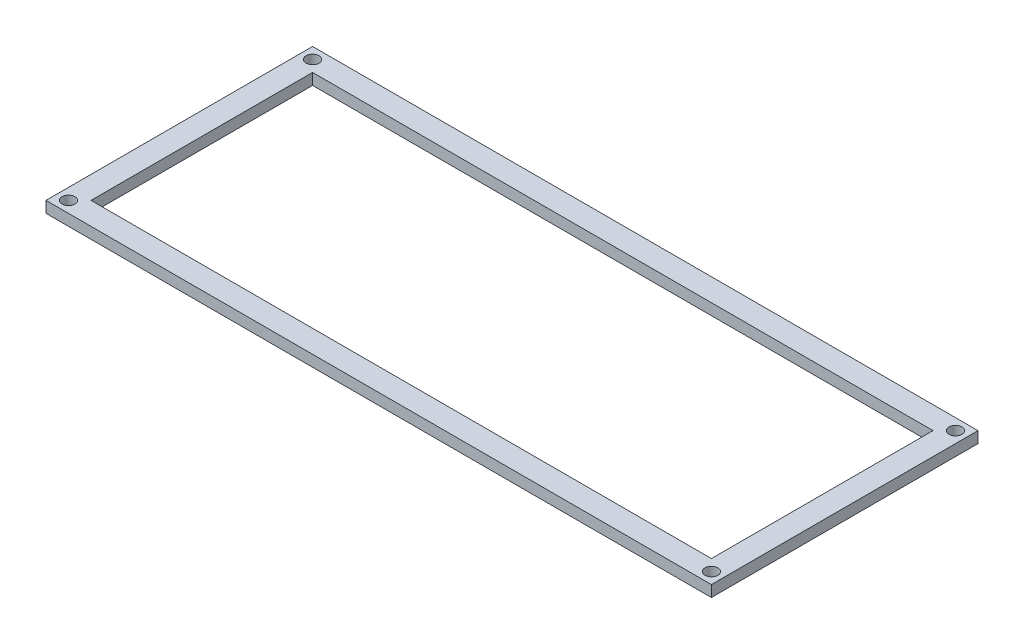
from build123d import *

# Parameters (mm, degrees)
SKETCH1_W                           = 150.159999908
SKETCH1_H                           = 60.160000076
SKETCH1_W_2                         = 139.999999908
SKETCH1_H_2                         = 50.000000076
BOSS_EXTRUDE1_DEPTH                 = 2.54
SKETCH2_R                           = 1.4605
MOUNTING_HOLES_4_40_CLEARANCE_DEPTH = 2.54


with BuildPart() as part:
    # Sketch1 → Boss-Extrude1 (new body)
    with BuildSketch(Plane(origin=(0, 0, 0), x_dir=(1, 0, 0), z_dir=(0, 1, 0))):
        Rectangle(SKETCH1_W, SKETCH1_H)
        Rectangle(SKETCH1_W_2, SKETCH1_H_2, mode=Mode.SUBTRACT)
    extrude(amount=BOSS_EXTRUDE1_DEPTH)

    # Sketch2 → Mounting Holes (4-40 Clearance) (cut)
    with BuildSketch(Plane(origin=(0, 2.54, 0), x_dir=(1, 0, 0), z_dir=(0, 1, 0))):
        with Locations((72.539999954, -27.540000038)):
            Circle(SKETCH2_R)
        with Locations((72.539999954, 27.540000038)):
            Circle(SKETCH2_R)
        with Locations((-72.539999954, 27.540000038)):
            Circle(SKETCH2_R)
        with Locations((-72.539999954, -27.540000038)):
            Circle(SKETCH2_R)
    extrude(amount=-MOUNTING_HOLES_4_40_CLEARANCE_DEPTH, mode=Mode.SUBTRACT)


solid = part.part
